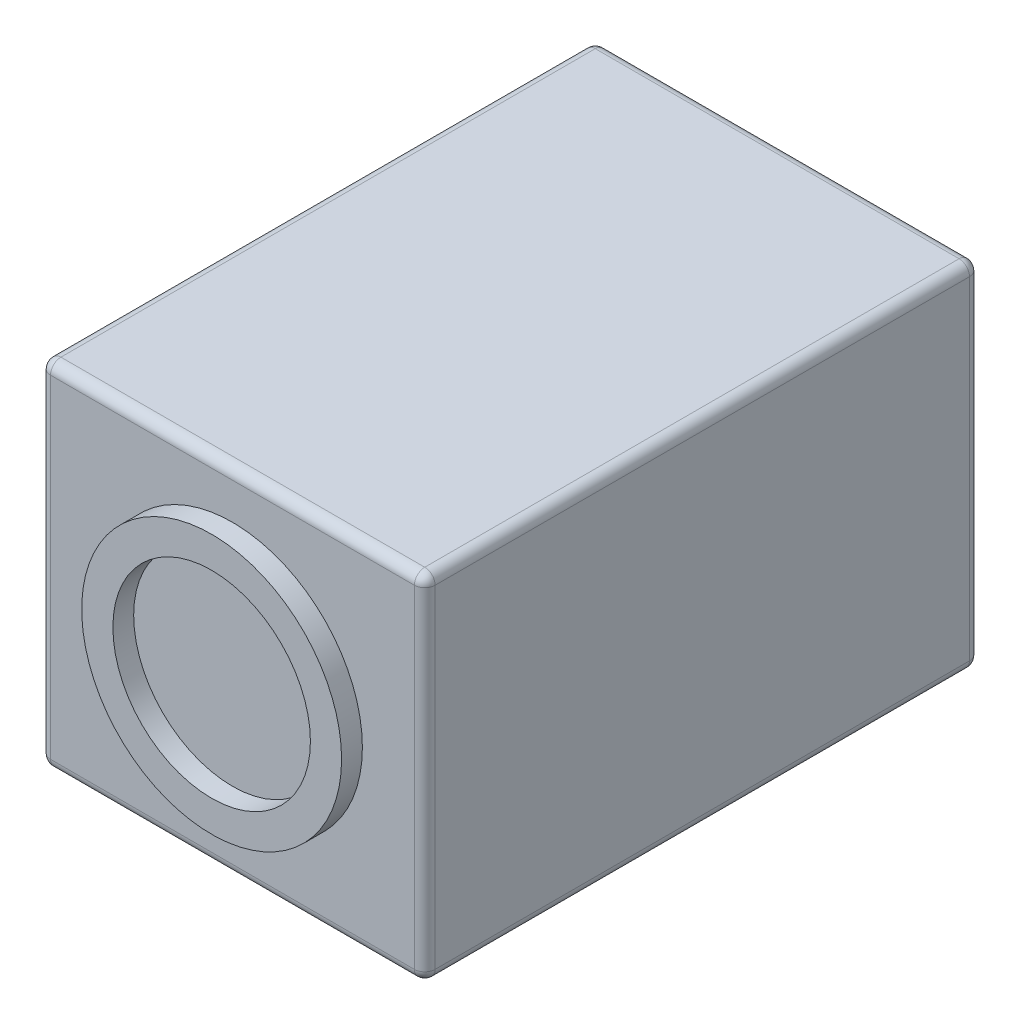
from build123d import *

# Parameters (mm, degrees)
SKETCH1_W          = 46.99
SKETCH1_H          = 43.18
EXTRUDE1_DEPTH     = 67.818
FILLET2_R          = 1.27
SKETCH2_R          = 15.875
SKETCH2_R_2        = 12.065
EXTRUDE2_DEPTH     = 2.54
SKETCH3_R          = 1.0795
CUT_EXTRUDE1_DEPTH = 2.54


with BuildPart() as part:
    # Sketch1 → Extrude1 (new body)
    with BuildSketch(Plane.XY):
        Rectangle(SKETCH1_W, SKETCH1_H)
    extrude(amount=EXTRUDE1_DEPTH)

    # Fillet2
    fillet2_edges = [part.edges().sort_by_distance(p)[0] for p in [
        (23.495, 0, 67.818),
        (0, 21.59, 67.818),
        (-23.495, 0, 67.818),
        (0, 21.59, 0),
        (23.495, 0, 0),
        (0, -21.59, 0),
        (-23.495, 0, 0),
        (0, -21.59, 67.818),
        (-23.495, 21.59, 33.909),
        (23.495, 21.59, 33.909),
        (23.495, -21.59, 33.909),
        (-23.495, -21.59, 33.909),
    ]]
    fillet(fillet2_edges, radius=FILLET2_R)

    # Sketch2 → Extrude2 (add)
    with BuildSketch(Plane.XY.offset(67.818)):
        Circle(SKETCH2_R)
        Circle(SKETCH2_R_2, mode=Mode.SUBTRACT)
    extrude(amount=EXTRUDE2_DEPTH)

    # Sketch3 → Cut-Extrude1 (cut)
    with BuildSketch(Plane.XZ.offset(21.59)):
        with Locations((-10.922, 39.1795)):
            Circle(SKETCH3_R)
        with Locations((10.795, 39.1795)):
            Circle(SKETCH3_R)
    extrude(amount=-CUT_EXTRUDE1_DEPTH, mode=Mode.SUBTRACT)


solid = part.part
